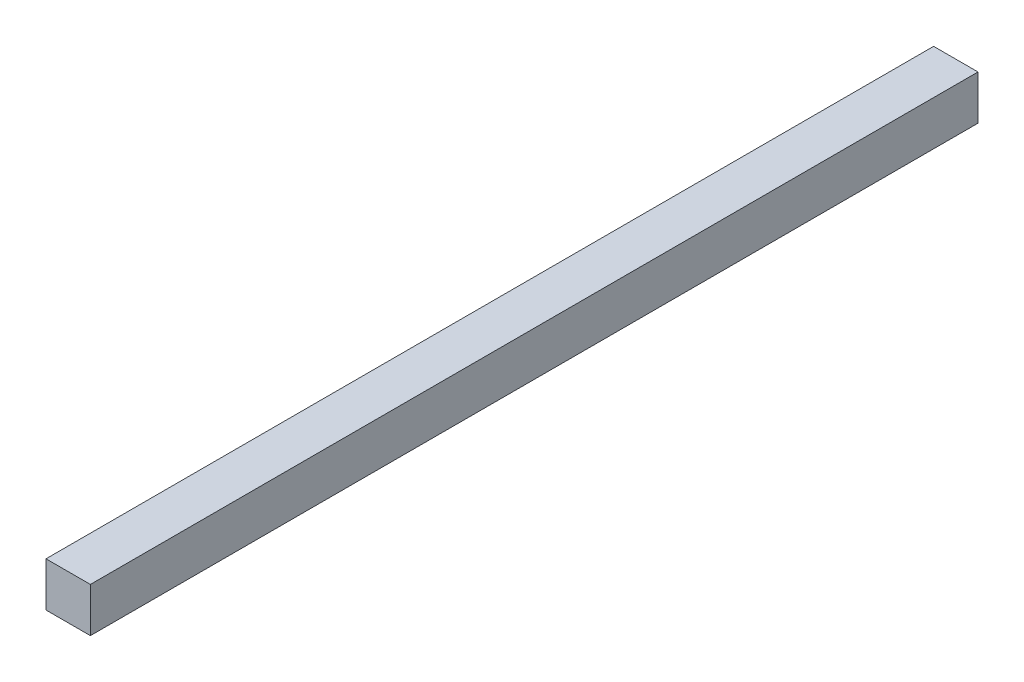
from build123d import *

# Parameters (mm, degrees)
SKETCH_1_W      = 20
SKETCH_1_H      = 20
EXTRUDE_1_DEPTH = 400


with BuildPart() as part:
    # 草图1 → 凸台-拉伸1 (new body)
    with BuildSketch(Plane.XY):
        with Locations((-11.840490798, 13.466585539)):
            Rectangle(SKETCH_1_W, SKETCH_1_H)
    extrude(amount=EXTRUDE_1_DEPTH)


solid = part.part
